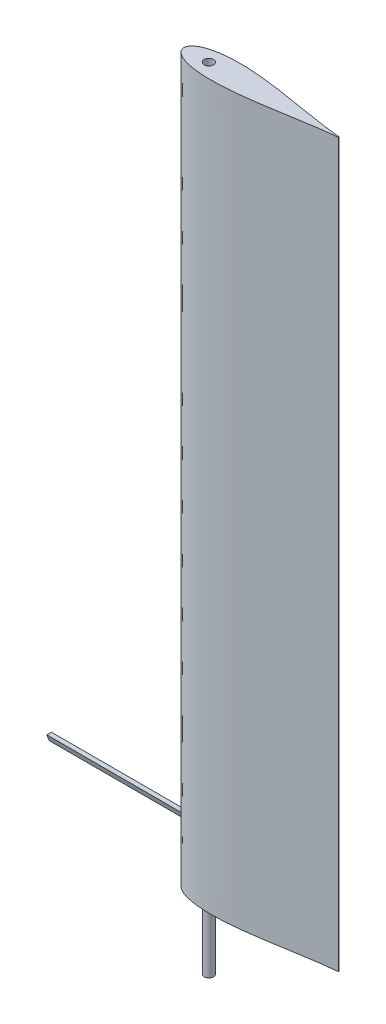
from build123d import *

# Parameters (mm, degrees)
BOSS_EXTRUDE2_DEPTH = 2997.2
SKETCH3_R           = 19.05
BOSS_EXTRUDE3_DEPTH = 279.4
BOSS_EXTRUDE4_DEPTH = 558.8


with BuildPart() as part:
    # Sketch2 → Boss-Extrude2 (new body)
    with BuildSketch(Plane(origin=(0, 0, 0), x_dir=(1, 0, 0), z_dir=(0, 1, 0))):
        with BuildLine():
            ThreePointArc((1549.501563464, 1054.430155843), (1549.08218451, 1055.50516717), (1548.045627141, 1056.012194665))
            add(Edge.make_bspline(
                [(1548.045627141, 1056.012194665), (1542.909791323, 1056.472519013), (1530.540909696, 1057.58114039), (1510.986556039, 1059.816213412), (1482.177884589, 1063.526776902), (1446.257152965, 1068.830094812), (1403.24224431, 1075.757081034), (1360.266558732, 1082.923578828), (1317.282336171, 1090.038800752), (1274.245745344, 1096.833109902), (1235.909717346, 1102.343296296), (1202.288019328, 1106.58475046), (1173.410335805, 1109.722628213), (1144.472152594, 1112.250283696), (1115.477538312, 1114.035552823), (1086.440285904, 1114.91850176), (1061.259922028, 1114.727950405), (1039.978587587, 1113.761025966), (1022.600495844, 1112.398571136), (1005.28616565, 1110.369387303), (988.081449654, 1107.548738994), (973.183943905, 1104.239887104), (960.605062366, 1100.668583987), (950.293736789, 1097.13582835), (940.233035207, 1092.935600496), (931.622325068, 1088.469898534), (924.483129487, 1083.888000396), (918.748261755, 1079.408348845), (914.008545213, 1074.700339431), (910.322770867, 1069.87124211), (907.699650062, 1065.078330087), (905.889335524, 1059.882116762), (905.652910054, 1056.246848831), (905.534758532, 1054.430156076)],
                knots=[0, 0, 0, 0, 0.023121883, 0.055685548, 0.088247664, 0.15337109, 0.21849516, 0.283619423, 0.348743655, 0.413867682, 0.478991363, 0.522407389, 0.565823311, 0.609239115, 0.652654647, 0.696069819, 0.739484349, 0.76553436, 0.791584249, 0.817634087, 0.843683681, 0.869732753, 0.886015097, 0.902297612, 0.91858044, 0.934862883, 0.94572109, 0.956578978, 0.967437024, 0.975584777, 0.98372934, 0.991868883, 1, 1, 1, 1], degree=3))
            add(Edge.make_bspline(
                [(905.534758532, 1054.430156076), (905.652910039, 1052.613463015), (905.88933546, 1048.978194781), (907.699649807, 1043.781981262), (910.322771314, 1038.98906985), (914.008544543, 1034.159972218), (918.748262951, 1029.451964506), (924.483128543, 1024.972310552), (931.622325102, 1020.390413689), (940.233036612, 1015.924714877), (950.293735449, 1011.724480454), (960.605062585, 1008.191728555), (973.18394417, 1004.620427227), (988.081450073, 1001.311576473), (1005.28616494, 998.490920502), (1022.600496189, 996.461744206), (1039.978587645, 995.099288886), (1061.259921893, 994.132357669), (1086.440285899, 993.94180969), (1115.477538494, 994.824755562), (1144.472152215, 996.610033065), (1173.410336049, 999.137680365), (1202.288019296, 1002.275560259), (1235.909717341, 1006.517013927), (1274.24574555, 1012.027199725), (1317.282335886, 1018.821512255), (1360.266558748, 1025.93673228), (1403.242244502, 1033.103228848), (1446.25715298, 1040.030216421), (1482.177884301, 1045.333537131), (1510.986556242, 1049.044096892), (1530.540909566, 1051.279172408), (1542.909791307, 1052.387792672), (1548.045625368, 1052.848116875)],
                knots=[0, 0, 0, 0, 0.008131119, 0.016270661, 0.024415224, 0.032562977, 0.043421021, 0.05427891, 0.065137117, 0.081419559, 0.097702389, 0.113984904, 0.130267246, 0.156316319, 0.182365913, 0.20841575, 0.23446564, 0.260515651, 0.303930181, 0.347345353, 0.390760886, 0.434176688, 0.477592611, 0.521008637, 0.586132318, 0.651256345, 0.716380577, 0.781504839, 0.84662891, 0.911752336, 0.944314452, 0.976878117, 1, 1, 1, 1], degree=3))
            ThreePointArc((1548.045625368, 1052.848116875), (1549.082183907, 1053.355143862), (1549.501563464, 1054.430155843))
        make_face()
        with BuildLine():
            ThreePointArc((1029.105776074, 1054.430155987), (1009.674776074, 1073.861155987), (990.243776074, 1054.430155987))
            ThreePointArc((990.243776074, 1054.430155987), (1009.674776074, 1034.999155987), (1029.105776074, 1054.430155987))
        make_face(mode=Mode.SUBTRACT)
    extrude(amount=BOSS_EXTRUDE2_DEPTH)


with BuildPart() as body_2:
    # Sketch3 → Boss-Extrude3 (new body)
    with BuildSketch(Plane.XZ):
        with Locations((1009.674776074, -1054.430155987)):
            Circle(SKETCH3_R)
    extrude(amount=BOSS_EXTRUDE3_DEPTH)


with BuildPart() as body_3:
    # Sketch4 → Boss-Extrude4 (new body)
    with BuildSketch(Plane(origin=(905.534758532, 0, 0), x_dir=(0, 0, -1), z_dir=(1, 0, 0))):
        Polygon((1063.955156076, 254), (1044.905156076, 254), (1054.430156076, 228.6), align=None)
    extrude(amount=-BOSS_EXTRUDE4_DEPTH)


solid = Compound([part.part, body_2.part, body_3.part])
